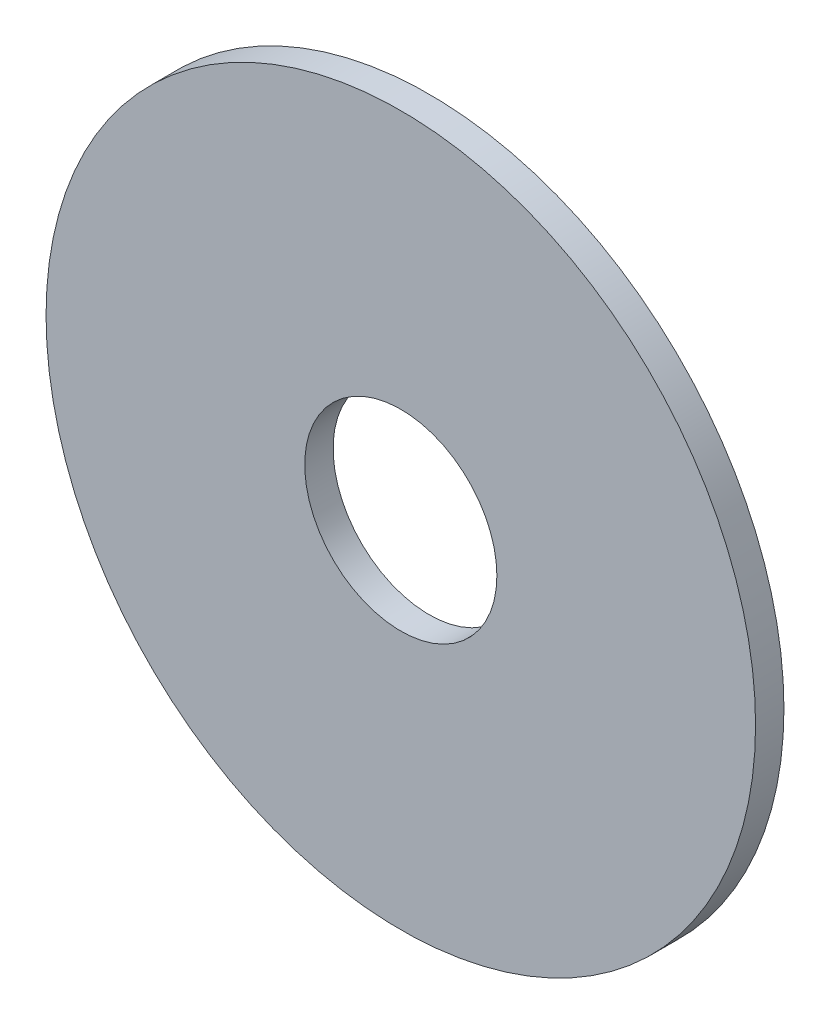
from build123d import *

# Parameters (mm, degrees)
SKETCH1_R      = 9.525
SKETCH1_R_2    = 2.5796875
EXTRUDE1_DEPTH = 0.762


with BuildPart() as part:
    # Sketch1 → Extrude1 (new body)
    with BuildSketch(Plane.XY):
        Circle(SKETCH1_R)
        Circle(SKETCH1_R_2, mode=Mode.SUBTRACT)
    extrude(amount=-EXTRUDE1_DEPTH)


solid = part.part
